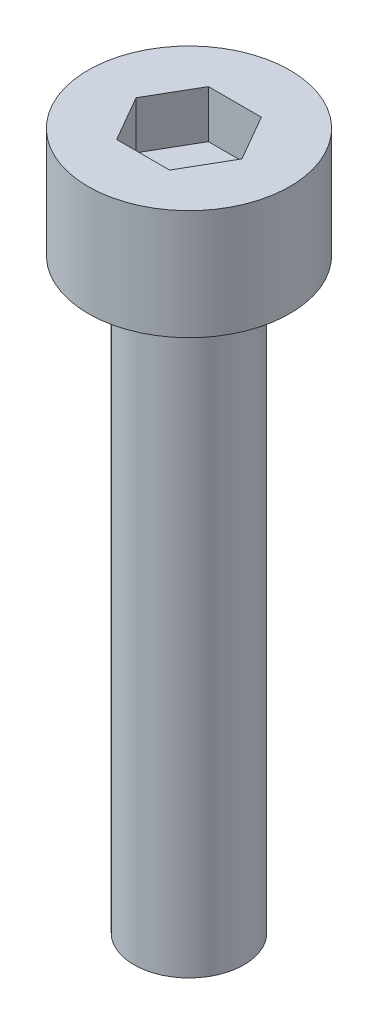
from build123d import *

# Parameters (mm, degrees)
SKETCH_1_R            = 2.75
EXTRUDE_248_DEPTH     = 3
CUT_EXTRUDE_378_DEPTH = 1.3
SKETCH_3_R            = 1.5
EXTRUDE_479_DEPTH     = 16


with BuildPart() as part:
    # 草图1 → Extrude 248 (new body)
    with BuildSketch(Plane(origin=(0, 0, 0), x_dir=(1, 0, 0), z_dir=(0, 1, 0))):
        Circle(SKETCH_1_R)
    extrude(amount=EXTRUDE_248_DEPTH)

    # 草图2 → Cut-Extrude 378 (cut)
    with BuildSketch(Plane(origin=(0, 3, 0), x_dir=(1, 0, 0), z_dir=(0, 1, 0))):
        Polygon((1.443375673, 0), (0.721687836, 1.25), (-0.721687836, 1.25), (-1.443375673, 0), (-0.721687836, -1.25), (0.721687836, -1.25), align=None)
    extrude(amount=-CUT_EXTRUDE_378_DEPTH, mode=Mode.SUBTRACT)

    # 草图3 → Extrude 479 (add)
    with BuildSketch(Plane.XZ):
        Circle(SKETCH_3_R)
    extrude(amount=EXTRUDE_479_DEPTH)


solid = part.part
